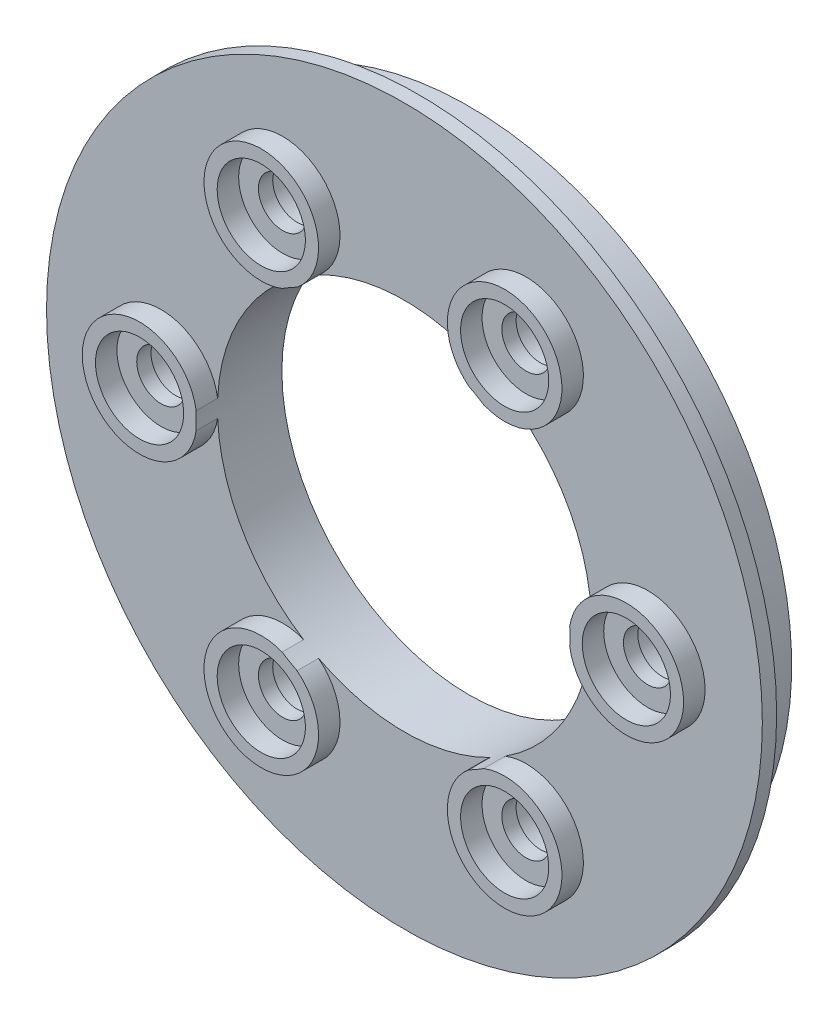
from build123d import *

# Parameters (mm, degrees)
SKETCH_1_W              = 25
SKETCH_1_H              = 1
SKETCH_2_R              = 22.55
EXTRUDE_1_DEPTH         = 6
SKETCH_3_W              = 4
SKETCH_3_H              = 1.5
SKETCH_4_W              = 4
SKETCH_4_H              = 1.5
SKETCH_5_W              = 4
SKETCH_5_H              = 1.5
SKETCH_6_W              = 4
SKETCH_6_H              = 1.5
SKETCH_7_W              = 4
SKETCH_7_H              = 1.5
SKETCH_8_W              = 4
SKETCH_8_H              = 1.5
HOLE_WIZARD_M24_1_D     = 26.12
HOLE_WIZARD_M24_1_DEPTH = 8.5
SKETCH_17_R             = 22.55
CUT_EXTRUDE_1_DEPTH     = 2.5


with BuildPart() as part:
    # 草图1 → 旋转1 (revolve)
    with BuildSketch(Plane(origin=(0, 0, 0), x_dir=(1, 0, 0), z_dir=(0, 1, 0))):
        with Locations((12.5, 22.5)):
            Rectangle(SKETCH_1_W, SKETCH_1_H)
    revolve(axis=Axis((0, 0, -23), (0, 0, 1)))

    # 草图2 → 凸台-拉伸1 (add)
    with BuildSketch(Plane(origin=(0, 0, -23), x_dir=(-1, 0, 0), z_dir=(0, 0, -1))):
        Circle(SKETCH_2_R)
    extrude(amount=EXTRUDE_1_DEPTH)

    # 草图3 → 旋转2 (revolve)
    with BuildSketch(Plane.XZ.offset(14.722431864)):
        with Locations((10.5, -21.25)):
            Rectangle(SKETCH_3_W, SKETCH_3_H)
    revolve(axis=Axis((8.5, -14.722431864, -20.5), (0, 0, -1)))

    # 草图4 → 旋转3 (revolve)
    with BuildSketch(Plane.XZ.offset(14.722431864)):
        with Locations((-6.5, -21.25)):
            Rectangle(SKETCH_4_W, SKETCH_4_H)
    revolve(axis=Axis((-8.5, -14.722431864, -20.5), (0, 0, -1)))

    # 草图5 → 旋转4 (revolve)
    with BuildSketch(Plane.XZ):
        with Locations((-15, -21.25)):
            Rectangle(SKETCH_5_W, SKETCH_5_H)
    revolve(axis=Axis((-17, 0, -20.5), (0, 0, -1)))

    # 草图6 → 旋转5 (revolve)
    with BuildSketch(Plane.XZ.offset(-14.722431864)):
        with Locations((-6.5, -21.25)):
            Rectangle(SKETCH_6_W, SKETCH_6_H)
    revolve(axis=Axis((-8.5, 14.722431864, -20.5), (0, 0, -1)))

    # 草图7 → 旋转6 (revolve)
    with BuildSketch(Plane.XZ.offset(-14.722431864)):
        with Locations((10.5, -21.25)):
            Rectangle(SKETCH_7_W, SKETCH_7_H)
    revolve(axis=Axis((8.5, 14.722431864, -20.5), (0, 0, -1)))

    # 草图8 → 旋转7 (revolve)
    with BuildSketch(Plane.XZ):
        with Locations((19, -21.25)):
            Rectangle(SKETCH_8_W, SKETCH_8_H)
    revolve(axis=Axis((17, 0, -20.5), (0, 0, -1)))

    # 草图9 → 切除-旋转1 (revolve, cut)
    with BuildSketch(Plane.XZ.offset(14.722431864)):
        Polygon((11.58, -20.5), (8.5, -20.5), (8.5, -29), (10.75, -29), (10.75, -23), (10.2, -23), (10.2, -22), (11.58, -22), align=None)
    revolve(axis=Axis((8.5, -14.722431864, -20.5), (0, 0, -1)), mode=Mode.SUBTRACT)

    # 草图10 → 切除-旋转2 (revolve, cut)
    with BuildSketch(Plane.XZ.offset(14.722431864)):
        Polygon((-5.42, -20.5), (-8.5, -20.5), (-8.5, -29), (-6.25, -29), (-6.25, -23), (-6.8, -23), (-6.8, -22), (-5.42, -22), align=None)
    revolve(axis=Axis((-8.5, -14.722431864, -20.5), (0, 0, -1)), mode=Mode.SUBTRACT)

    # 草图11 → 切除-旋转3 (revolve, cut)
    with BuildSketch(Plane.XZ):
        Polygon((-13.92, -20.5), (-17, -20.5), (-17, -29), (-14.75, -29), (-14.75, -23), (-15.3, -23), (-15.3, -22), (-13.92, -22), align=None)
    revolve(axis=Axis((-17, 0, -20.5), (0, 0, -1)), mode=Mode.SUBTRACT)

    # 草图12 → 切除-旋转4 (revolve, cut)
    with BuildSketch(Plane.XZ.offset(-14.722431864)):
        Polygon((-5.42, -20.5), (-8.5, -20.5), (-8.5, -29), (-6.25, -29), (-6.25, -23), (-6.8, -23), (-6.8, -22), (-5.42, -22), align=None)
    revolve(axis=Axis((-8.5, 14.722431864, -20.5), (0, 0, -1)), mode=Mode.SUBTRACT)

    # 草图13 → 切除-旋转5 (revolve, cut)
    with BuildSketch(Plane.XZ.offset(-14.722431864)):
        Polygon((11.58, -20.5), (8.5, -20.5), (8.5, -29), (10.75, -29), (10.75, -23), (10.2, -23), (10.2, -22), (11.58, -22), align=None)
    revolve(axis=Axis((8.5, 14.722431864, -20.5), (0, 0, -1)), mode=Mode.SUBTRACT)

    # 草图14 → 切除-旋转6 (revolve, cut)
    with BuildSketch(Plane.XZ):
        Polygon((20.08, -20.5), (17, -20.5), (17, -29), (19.25, -29), (19.25, -23), (18.7, -23), (18.7, -22), (20.08, -22), align=None)
    revolve(axis=Axis((17, 0, -20.5), (0, 0, -1)), mode=Mode.SUBTRACT)

    # M24 间隙孔1
    with Locations(Plane(origin=(0, 0, -29), x_dir=(-1, 0, 0), z_dir=(0, 0, -1))):
        with Locations((0, 0)):
            Hole(HOLE_WIZARD_M24_1_D / 2, depth=HOLE_WIZARD_M24_1_DEPTH)

    # 草图17 → 切除-拉伸1 (cut)
    with BuildSketch(Plane(origin=(0, 0, -29), x_dir=(-1, 0, 0), z_dir=(0, 0, -1))):
        Circle(SKETCH_17_R)
    extrude(amount=-CUT_EXTRUDE_1_DEPTH, mode=Mode.SUBTRACT)


solid = part.part
